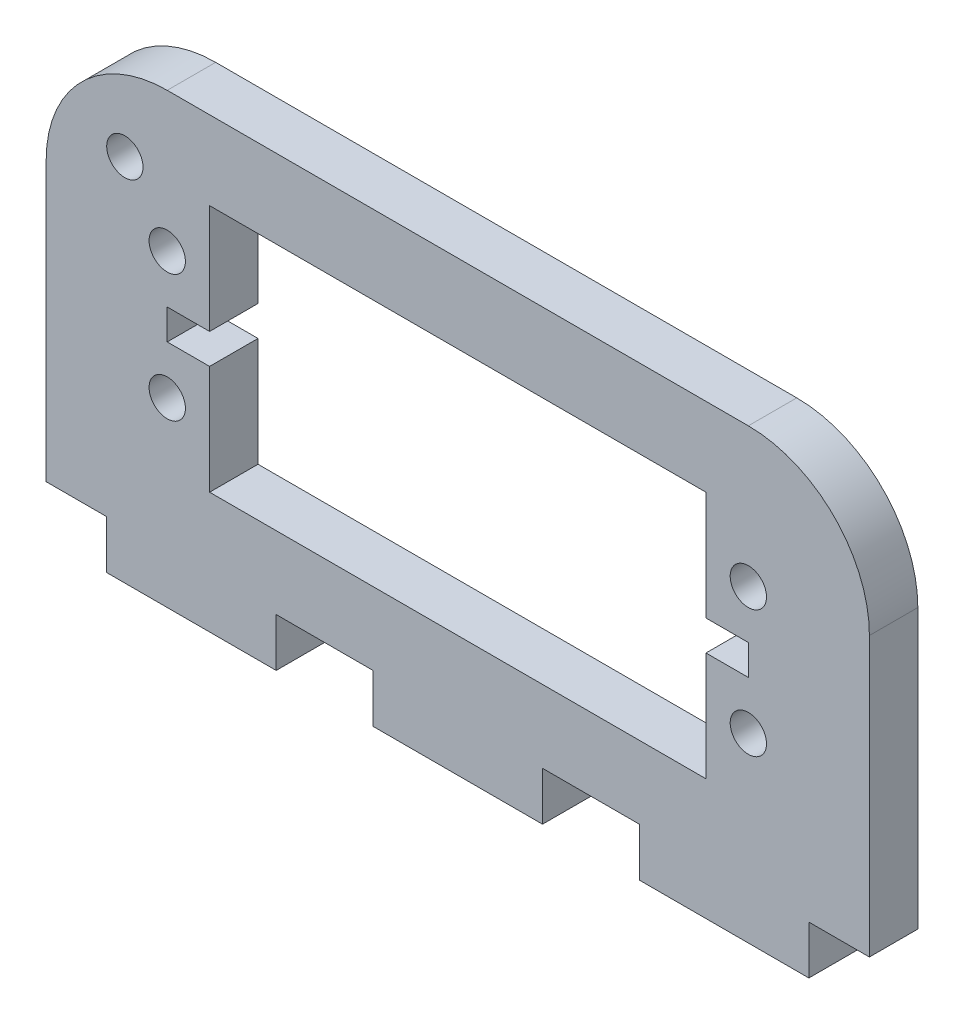
from build123d import *

# Parameters (mm, degrees)
SKETCH1_R           = 1.5
BOSS_EXTRUDE1_DEPTH = 4


with BuildPart() as part:
    # Sketch1 → Boss-Extrude1 (new body)
    with BuildSketch(Plane.XY):
        with BuildLine():
            Line((49.000000342, 3.999999998), (49.000000342, -2e-09))
            Line((49.000000342, -2e-09), (63.000000342, -2e-09))
            Line((63.000000342, -2e-09), (63.000000342, 3.999999998))
            Line((63.000000342, 3.999999998), (68.000000342, 3.999999998))
            Line((68.000000342, 3.999999998), (68.000000342, 26.999999998))
            ThreePointArc((68.000000342, 26.999999998), (65.071068153, 34.07106781), (58.000000342, 36.999999998))
            Line((58.000000342, 36.999999998), (10.000000342, 36.999999998))
            ThreePointArc((10.000000342, 36.999999998), (2.92893253, 34.07106781), (3.42e-07, 26.999999998))
            Line((3.42e-07, 26.999999998), (3.42e-07, 3.999999998))
            Line((3.42e-07, 3.999999998), (5.000000342, 3.999999998))
            Line((5.000000342, 3.999999998), (5.000000342, -2e-09))
            Line((5.000000342, -2e-09), (19.000000342, -2e-09))
            Line((19.000000342, -2e-09), (19.000000342, 3.999999998))
            Line((19.000000342, 3.999999998), (27.000000342, 3.999999998))
            Line((27.000000342, 3.999999998), (27.000000342, -2e-09))
            Line((27.000000342, -2e-09), (41.000000342, -2e-09))
            Line((41.000000342, -2e-09), (41.000000342, 3.999999998))
            Line((41.000000342, 3.999999998), (49.000000342, 3.999999998))
        make_face()
        with Locations((10.000000342, 14.999999998)):
            Circle(SKETCH1_R, mode=Mode.SUBTRACT)
        with Locations((10.000000342, 25.499999998)):
            Circle(SKETCH1_R, mode=Mode.SUBTRACT)
        with Locations((58.000000342, 14.999999998)):
            Circle(SKETCH1_R, mode=Mode.SUBTRACT)
        with Locations((58.000000342, 25.499999998)):
            Circle(SKETCH1_R, mode=Mode.SUBTRACT)
        with Locations((6.500000342, 30.499999998)):
            Circle(SKETCH1_R, mode=Mode.SUBTRACT)
        Polygon((54.500000342, 30.499999998), (54.500000342, 21.499999998), (58.000000342, 21.499999998), (58.000000342, 18.999999998), (54.500000342, 18.999999998), (54.500000342, 9.999999998), (13.500000342, 9.999999998), (13.500000342, 18.999999998), (10.000000342, 18.999999998), (10.000000342, 21.499999998), (13.500000342, 21.499999998), (13.500000342, 30.499999998), align=None, mode=Mode.SUBTRACT)
    extrude(amount=BOSS_EXTRUDE1_DEPTH)


solid = part.part
